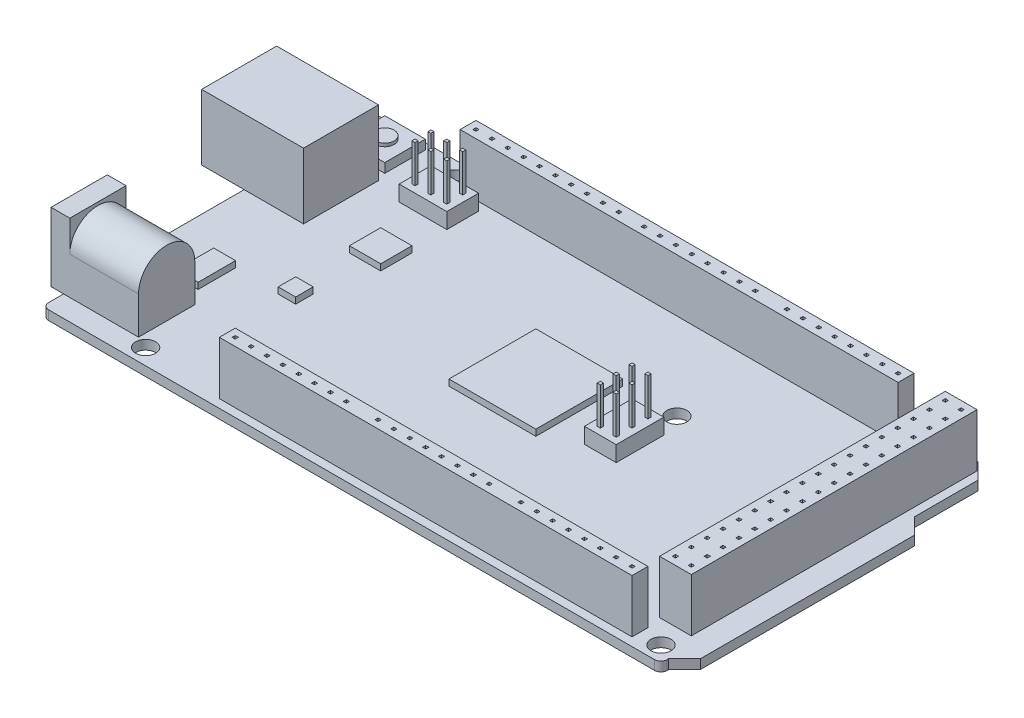
from build123d import *

# Parameters (mm, degrees)
BOSS_EXTRUDE1_DEPTH      = 1.5
FILLET1_R                = 1
SKETCH2_R                = 1.6
CUT_EXTRUDE1_DEPTH       = 59.477289609
SKETCH3_W                = 5.08
SKETCH3_H                = 45.72
BOSS_EXTRUDE2_DEPTH      = 8.5
SKETCH4_W                = 0.5
SKETCH4_H                = 0.5
CUT_EXTRUDE2_DEPTH       = 7
SKETCH5_W                = 12
SKETCH5_H                = 10.5
BOSS_EXTRUDE3_DEPTH      = 6.8
BOSS_EXTRUDE3_DEPTH_BACK = 9.5
SKETCH6_W                = 9
SKETCH6_H                = 11
BOSS_EXTRUDE4_DEPTH      = 2
BOSS_EXTRUDE4_DEPTH_BACK = 1
SKETCH7_R                = 4.5
BOSS_EXTRUDE5_DEPTH      = 11
SKETCH8_W                = 11
SKETCH8_H                = 9
BOSS_EXTRUDE6_DEPTH      = 6
CUT_EXTRUDE3_DEPTH       = 9
SKETCH10_W               = 5
SKETCH10_H               = 3.5
BOSS_EXTRUDE7_DEPTH      = 8.5
SKETCH11_W               = 13.9
SKETCH11_H               = 13.9
SKETCH11_W_2             = 5
SKETCH11_H_2             = 5
SKETCH11_W_3             = 2.8
SKETCH11_H_3             = 2.8
SKETCH11_W_4             = 3.5
SKETCH11_H_4             = 6
BOSS_EXTRUDE8_DEPTH      = 1
SKETCH12_R               = 3
CUT_EXTRUDE4_DEPTH       = 9.5
SKETCH13_R               = 1.25
BOSS_EXTRUDE9_DEPTH      = 7.5
FILLET2_R                = 1
SKETCH14_W               = 6.5
SKETCH14_H               = 6.5
BOSS_EXTRUDE10_DEPTH     = 1.5
SKETCH15_R               = 1.5
BOSS_EXTRUDE11_DEPTH     = 0.5
SKETCH16_W               = 5.08
SKETCH16_H               = 7.62
SKETCH16_W_2             = 7.62
SKETCH16_H_2             = 5.08
BOSS_EXTRUDE12_DEPTH     = 2.5
SKETCH17_W               = 0.5
SKETCH17_H               = 0.5
BOSS_EXTRUDE13_DEPTH     = 6


with BuildPart() as part:
    # Sketch1 → Boss-Extrude1 (new body)
    with BuildSketch(Plane(origin=(0, 0, 0), x_dir=(1, 0, 0), z_dir=(0, 1, 0))):
        Polygon((49.49, 24.11), (49.49, 13.95), (52.03, 11.41), (52.03, -22.85), (49.49, -25.39), (49.49, -26.65), (-49.49, -26.65), (-49.49, 26.65), (46.95, 26.65), align=None)
    extrude(amount=BOSS_EXTRUDE1_DEPTH)

    # Fillet1
    fillet1_edges = [part.edges().sort_by_distance(p)[0] for p in [
        (-49.49, 0.75, -26.65),
        (49.49, 0.75, 26.65),
        (-49.49, 0.75, 26.65),
    ]]
    fillet(fillet1_edges, radius=FILLET1_R)

    # Sketch2 → Cut-Extrude1 (cut, through all)
    with BuildSketch(Plane(origin=(0, 1.5, 0), x_dir=(1, 0, 0), z_dir=(0, 1, 0))):
        with Locations(Location((46.98, -24.11, 0), (0, 0, 270))):
            Circle(SKETCH2_R)
        with Locations(Location((40.62, 24.11, 0), (0, 0, 270))):
            Circle(SKETCH2_R)
        with Locations(Location((-34.26, 24.11, 0), (0, 0, 270))):
            Circle(SKETCH2_R)
        with Locations(Location((-35.49, -24.11, 0), (0, 0, 270))):
            Circle(SKETCH2_R)
        with Locations(Location((16.53, -19.03, 0), (0, 0, 270))):
            Circle(SKETCH2_R)
        with Locations(Location((16.53, 8.88, 0), (0, 0, 270))):
            Circle(SKETCH2_R)
    extrude(amount=-CUT_EXTRUDE1_DEPTH, mode=Mode.SUBTRACT)

    # Sketch3 → Boss-Extrude2 (add)
    with BuildSketch(Plane(origin=(0, 1.5, 0), x_dir=(1, 0, 0), z_dir=(0, 1, 0))):
        Polygon((-22.51, -22.76), (-2.19, -22.76), (0.35, -22.76), (20.67, -22.76), (23.21, -22.76), (43.53, -22.76), (43.53, -25.3), (23.21, -25.3), (20.67, -25.3), (0.35, -25.3), (-2.19, -25.3), (-22.51, -25.3), align=None)
        with Locations((45.6, 2.44)):
            Rectangle(SKETCH3_W, SKETCH3_H)
        Polygon((38.06, 25.3), (17.74, 25.3), (15.2, 25.3), (-5.12, 25.3), (-6.64, 25.3), (-32.04, 25.3), (-32.04, 22.76), (-6.64, 22.76), (-5.12, 22.76), (15.2, 22.76), (17.74, 22.76), (38.06, 22.76), align=None)
    extrude(amount=BOSS_EXTRUDE2_DEPTH)

    # Sketch4 → Cut-Extrude2 (cut)
    with BuildSketch(Plane(origin=(0, 10, 0), x_dir=(1, 0, 0), z_dir=(0, 1, 0))):
        with Locations((-21.24, -24.03)):
            Rectangle(SKETCH4_W, SKETCH4_H)
        with Locations((-18.7, -24.03)):
            Rectangle(SKETCH4_W, SKETCH4_H)
        with Locations((-16.16, -24.03)):
            Rectangle(SKETCH4_W, SKETCH4_H)
        with Locations((-13.62, -24.03)):
            Rectangle(SKETCH4_W, SKETCH4_H)
        with Locations((-11.08, -24.03)):
            Rectangle(SKETCH4_W, SKETCH4_H)
        with Locations((-8.54, -24.03)):
            Rectangle(SKETCH4_W, SKETCH4_H)
        with Locations((-6, -24.03)):
            Rectangle(SKETCH4_W, SKETCH4_H)
        with Locations((-3.46, -24.03)):
            Rectangle(SKETCH4_W, SKETCH4_H)
        with Locations((1.62, -24.03)):
            Rectangle(SKETCH4_W, SKETCH4_H)
        with Locations((4.16, -24.03)):
            Rectangle(SKETCH4_W, SKETCH4_H)
        with Locations((6.7, -24.03)):
            Rectangle(SKETCH4_W, SKETCH4_H)
        with Locations((9.24, -24.03)):
            Rectangle(SKETCH4_W, SKETCH4_H)
        with Locations((11.78, -24.03)):
            Rectangle(SKETCH4_W, SKETCH4_H)
        with Locations((14.32, -24.03)):
            Rectangle(SKETCH4_W, SKETCH4_H)
        with Locations((16.86, -24.03)):
            Rectangle(SKETCH4_W, SKETCH4_H)
        with Locations((19.4, -24.03)):
            Rectangle(SKETCH4_W, SKETCH4_H)
        with Locations((24.48, -24.03)):
            Rectangle(SKETCH4_W, SKETCH4_H)
        with Locations((27.02, -24.03)):
            Rectangle(SKETCH4_W, SKETCH4_H)
        with Locations((29.56, -24.03)):
            Rectangle(SKETCH4_W, SKETCH4_H)
        with Locations((32.1, -24.03)):
            Rectangle(SKETCH4_W, SKETCH4_H)
        with Locations((34.64, -24.03)):
            Rectangle(SKETCH4_W, SKETCH4_H)
        with Locations((37.18, -24.03)):
            Rectangle(SKETCH4_W, SKETCH4_H)
        with Locations((39.72, -24.03)):
            Rectangle(SKETCH4_W, SKETCH4_H)
        with Locations((42.26, -24.03)):
            Rectangle(SKETCH4_W, SKETCH4_H)
        with Locations((46.87, -19.15)):
            Rectangle(SKETCH4_W, SKETCH4_H)
        with Locations((44.33, -19.15)):
            Rectangle(SKETCH4_W, SKETCH4_H)
        with Locations((46.87, -16.61)):
            Rectangle(SKETCH4_W, SKETCH4_H)
        with Locations((44.33, -16.61)):
            Rectangle(SKETCH4_W, SKETCH4_H)
        with Locations((46.87, -14.07)):
            Rectangle(SKETCH4_W, SKETCH4_H)
        with Locations((44.33, -14.07)):
            Rectangle(SKETCH4_W, SKETCH4_H)
        with Locations((46.87, -11.53)):
            Rectangle(SKETCH4_W, SKETCH4_H)
        with Locations((44.33, -11.53)):
            Rectangle(SKETCH4_W, SKETCH4_H)
        with Locations((46.87, -8.99)):
            Rectangle(SKETCH4_W, SKETCH4_H)
        with Locations((44.33, -8.99)):
            Rectangle(SKETCH4_W, SKETCH4_H)
        with Locations((46.87, -6.45)):
            Rectangle(SKETCH4_W, SKETCH4_H)
        with Locations((44.33, -6.45)):
            Rectangle(SKETCH4_W, SKETCH4_H)
        with Locations((46.87, -3.91)):
            Rectangle(SKETCH4_W, SKETCH4_H)
        with Locations((44.33, -3.91)):
            Rectangle(SKETCH4_W, SKETCH4_H)
        with Locations((46.87, -1.37)):
            Rectangle(SKETCH4_W, SKETCH4_H)
        with Locations((44.33, -1.37)):
            Rectangle(SKETCH4_W, SKETCH4_H)
        with Locations((46.87, 1.17)):
            Rectangle(SKETCH4_W, SKETCH4_H)
        with Locations((44.33, 1.17)):
            Rectangle(SKETCH4_W, SKETCH4_H)
        with Locations((46.87, 3.71)):
            Rectangle(SKETCH4_W, SKETCH4_H)
        with Locations((44.33, 3.71)):
            Rectangle(SKETCH4_W, SKETCH4_H)
        with Locations((46.87, 6.25)):
            Rectangle(SKETCH4_W, SKETCH4_H)
        with Locations((44.33, 6.25)):
            Rectangle(SKETCH4_W, SKETCH4_H)
        with Locations((46.87, 8.79)):
            Rectangle(SKETCH4_W, SKETCH4_H)
        with Locations((44.33, 8.79)):
            Rectangle(SKETCH4_W, SKETCH4_H)
        with Locations((46.87, 11.33)):
            Rectangle(SKETCH4_W, SKETCH4_H)
        with Locations((44.33, 11.33)):
            Rectangle(SKETCH4_W, SKETCH4_H)
        with Locations((46.87, 13.87)):
            Rectangle(SKETCH4_W, SKETCH4_H)
        with Locations((44.33, 13.87)):
            Rectangle(SKETCH4_W, SKETCH4_H)
        with Locations((46.87, 16.41)):
            Rectangle(SKETCH4_W, SKETCH4_H)
        with Locations((44.33, 16.41)):
            Rectangle(SKETCH4_W, SKETCH4_H)
        with Locations((46.87, 18.95)):
            Rectangle(SKETCH4_W, SKETCH4_H)
        with Locations((44.33, 18.95)):
            Rectangle(SKETCH4_W, SKETCH4_H)
        with Locations((46.87, 21.49)):
            Rectangle(SKETCH4_W, SKETCH4_H)
        with Locations((44.33, 21.49)):
            Rectangle(SKETCH4_W, SKETCH4_H)
        with Locations((46.87, 24.03)):
            Rectangle(SKETCH4_W, SKETCH4_H)
        with Locations((44.33, 24.03)):
            Rectangle(SKETCH4_W, SKETCH4_H)
        with Locations((36.79, 24.03)):
            Rectangle(SKETCH4_W, SKETCH4_H)
        with Locations((34.25, 24.03)):
            Rectangle(SKETCH4_W, SKETCH4_H)
        with Locations((31.71, 24.03)):
            Rectangle(SKETCH4_W, SKETCH4_H)
        with Locations((29.17, 24.03)):
            Rectangle(SKETCH4_W, SKETCH4_H)
        with Locations((26.63, 24.03)):
            Rectangle(SKETCH4_W, SKETCH4_H)
        with Locations((24.09, 24.03)):
            Rectangle(SKETCH4_W, SKETCH4_H)
        with Locations((21.55, 24.03)):
            Rectangle(SKETCH4_W, SKETCH4_H)
        with Locations((19.01, 24.03)):
            Rectangle(SKETCH4_W, SKETCH4_H)
        with Locations((13.93, 24.03)):
            Rectangle(SKETCH4_W, SKETCH4_H)
        with Locations((11.39, 24.03)):
            Rectangle(SKETCH4_W, SKETCH4_H)
        with Locations((8.85, 24.03)):
            Rectangle(SKETCH4_W, SKETCH4_H)
        with Locations((6.31, 24.03)):
            Rectangle(SKETCH4_W, SKETCH4_H)
        with Locations((3.77, 24.03)):
            Rectangle(SKETCH4_W, SKETCH4_H)
        with Locations((1.23, 24.03)):
            Rectangle(SKETCH4_W, SKETCH4_H)
        with Locations((-1.31, 24.03)):
            Rectangle(SKETCH4_W, SKETCH4_H)
        with Locations((-3.85, 24.03)):
            Rectangle(SKETCH4_W, SKETCH4_H)
        with Locations((-7.91, 24.03)):
            Rectangle(SKETCH4_W, SKETCH4_H)
        with Locations((-10.45, 24.03)):
            Rectangle(SKETCH4_W, SKETCH4_H)
        with Locations((-12.99, 24.03)):
            Rectangle(SKETCH4_W, SKETCH4_H)
        with Locations((-15.53, 24.03)):
            Rectangle(SKETCH4_W, SKETCH4_H)
        with Locations((-18.07, 24.03)):
            Rectangle(SKETCH4_W, SKETCH4_H)
        with Locations((-20.61, 24.03)):
            Rectangle(SKETCH4_W, SKETCH4_H)
        with Locations((-23.15, 24.03)):
            Rectangle(SKETCH4_W, SKETCH4_H)
        with Locations((-25.69, 24.03)):
            Rectangle(SKETCH4_W, SKETCH4_H)
        with Locations((-28.23, 24.03)):
            Rectangle(SKETCH4_W, SKETCH4_H)
        with Locations((-30.77, 24.03)):
            Rectangle(SKETCH4_W, SKETCH4_H)
    extrude(amount=-CUT_EXTRUDE2_DEPTH, mode=Mode.SUBTRACT)

    # Sketch5 → Boss-Extrude3 (add, two sides)
    with BuildSketch(Plane.ZY.offset(49.49)) as boss_extrude3_sk:
        with Locations((-11.65, 6.75)):
            Rectangle(SKETCH5_W, SKETCH5_H)
    extrude(amount=BOSS_EXTRUDE3_DEPTH)
    extrude(boss_extrude3_sk.sketch, amount=-BOSS_EXTRUDE3_DEPTH_BACK)



with BuildPart() as body_2:
    # Sketch6 → Boss-Extrude4 (new, two sides)
    with BuildSketch(Plane.ZY.offset(49.49)) as boss_extrude4_sk:
        with Locations((18.75, 7)):
            Rectangle(SKETCH6_W, SKETCH6_H)
    extrude(amount=BOSS_EXTRUDE4_DEPTH)
    extrude(boss_extrude4_sk.sketch, amount=-BOSS_EXTRUDE4_DEPTH_BACK)


with BuildPart() as part_1:
    add(part.part)

    add(body_2.part)  # Boss-Extrude5 merges body 2
    # Sketch7 → Boss-Extrude5 (add)
    with BuildSketch(Plane(origin=(-48.49, 0, 0), x_dir=(0, 0, -1), z_dir=(1, 0, 0))):
        with Locations((-18.75, 7.5)):
            Circle(SKETCH7_R)
    extrude(amount=BOSS_EXTRUDE5_DEPTH)

    # Sketch8 → Boss-Extrude6 (add)
    with BuildSketch(Plane(origin=(0, 1.5, 0), x_dir=(1, 0, 0), z_dir=(0, 1, 0))):
        with Locations((-42.99, -18.75)):
            Rectangle(SKETCH8_W, SKETCH8_H)
    extrude(amount=BOSS_EXTRUDE6_DEPTH)

    # Sketch9 → Cut-Extrude3 (cut)
    with BuildSketch(Plane.ZY.offset(56.29)):
        Polygon((-14.15, 10.5), (-9.15, 10.5), (-7.65, 9), (-7.65, 2.5), (-15.65, 2.5), (-15.65, 9), align=None)
    extrude(amount=-CUT_EXTRUDE3_DEPTH, mode=Mode.SUBTRACT)

    # Sketch10 → Boss-Extrude7 (add)
    with BuildSketch(Plane.ZY.offset(47.29)):
        with Locations((-11.65, 6.5)):
            Rectangle(SKETCH10_W, SKETCH10_H)
    extrude(amount=BOSS_EXTRUDE7_DEPTH)

    # Sketch11 → Boss-Extrude8 (add)
    with BuildSketch(Plane(origin=(0, 1.5, 0), x_dir=(1, 0, 0), z_dir=(0, 1, 0))):
        with Locations((1.09, 1.75)):
            Rectangle(SKETCH11_W, SKETCH11_H)
        with Locations((-29.79, 7.8)):
            Rectangle(SKETCH11_W_2, SKETCH11_H_2)
        with Locations((-30.89, -4.7)):
            Rectangle(SKETCH11_W_3, SKETCH11_H_3)
        with Locations((-41.090307387, -8.878300353)):
            Rectangle(SKETCH11_W_4, SKETCH11_H_4)
    extrude(amount=BOSS_EXTRUDE8_DEPTH)

    # Sketch12 → Cut-Extrude4 (cut)
    with BuildSketch(Plane.ZY.offset(51.49)):
        with Locations((18.75, 8)):
            Circle(SKETCH12_R)
    extrude(amount=-CUT_EXTRUDE4_DEPTH, mode=Mode.SUBTRACT)

    # Sketch13 → Boss-Extrude9 (add)
    with BuildSketch(Plane.ZY.offset(41.99)):
        with Locations((18.75, 8)):
            Circle(SKETCH13_R)
    extrude(amount=BOSS_EXTRUDE9_DEPTH)

    # Fillet2
    fillet2_edges = [part_1.edges().sort_by_distance(p)[0] for p in [
        (-49.49, 8, 17.5),
    ]]
    fillet(fillet2_edges, radius=FILLET2_R)

    # Sketch14 → Boss-Extrude10 (add)
    with BuildSketch(Plane(origin=(0, 1.5, 0), x_dir=(1, 0, 0), z_dir=(0, 1, 0))):
        with Locations((-43.74, 22.4)):
            Rectangle(SKETCH14_W, SKETCH14_H)
    extrude(amount=BOSS_EXTRUDE10_DEPTH)

    # Sketch15 → Boss-Extrude11 (add)
    with BuildSketch(Plane(origin=(0, 3, 0), x_dir=(1, 0, 0), z_dir=(0, 1, 0))):
        with Locations(Location((-43.74, 22.4, 0), (0, 0, 270))):
            Circle(SKETCH15_R)
    extrude(amount=BOSS_EXTRUDE11_DEPTH)

    # Sketch16 → Boss-Extrude12 (add)
    with BuildSketch(Plane(origin=(0, 1.5, 0), x_dir=(1, 0, 0), z_dir=(0, 1, 0))):
        with Locations((15.58, 1.39)):
            Rectangle(SKETCH16_W, SKETCH16_H)
        with Locations((-31.55, 18.87)):
            Rectangle(SKETCH16_W_2, SKETCH16_H_2)
    extrude(amount=BOSS_EXTRUDE12_DEPTH)

    # Sketch17 → Boss-Extrude13 (add)
    with BuildSketch(Plane(origin=(0, 4, 0), x_dir=(1, 0, 0), z_dir=(0, 1, 0))):
        with Locations((-34.09, 17.6)):
            Rectangle(SKETCH17_W, SKETCH17_H)
        with Locations((-34.09, 20.14)):
            Rectangle(SKETCH17_W, SKETCH17_H)
        with Locations((16.85, -1.15)):
            Rectangle(SKETCH17_W, SKETCH17_H)
        with Locations((14.31, -1.15)):
            Rectangle(SKETCH17_W, SKETCH17_H)
        with Locations((-31.55, 20.14)):
            Rectangle(SKETCH17_W, SKETCH17_H)
        with Locations((-31.55, 17.6)):
            Rectangle(SKETCH17_W, SKETCH17_H)
        with Locations((-29.01, 20.14)):
            Rectangle(SKETCH17_W, SKETCH17_H)
        with Locations((-29.01, 17.6)):
            Rectangle(SKETCH17_W, SKETCH17_H)
        with Locations((14.31, 1.39)):
            Rectangle(SKETCH17_W, SKETCH17_H)
        with Locations((16.85, 1.39)):
            Rectangle(SKETCH17_W, SKETCH17_H)
        with Locations((14.31, 3.93)):
            Rectangle(SKETCH17_W, SKETCH17_H)
        with Locations((16.85, 3.93)):
            Rectangle(SKETCH17_W, SKETCH17_H)
    extrude(amount=BOSS_EXTRUDE13_DEPTH)


solid = part_1.part
